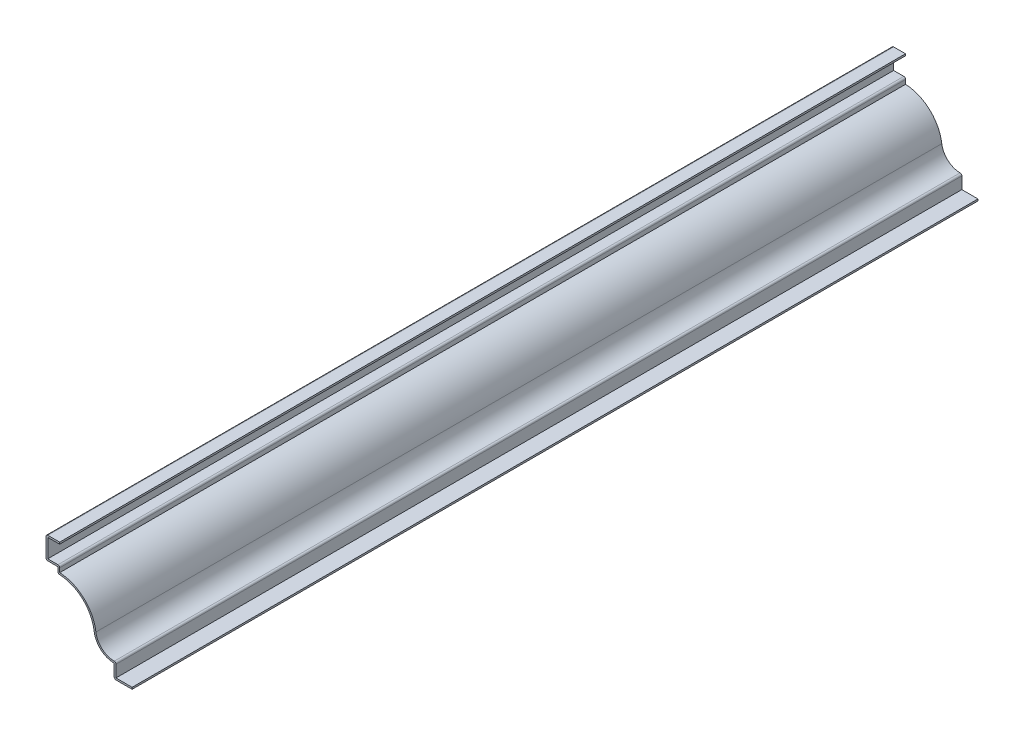
from build123d import *

# Parameters (mm, degrees)
EXTRUDE_THIN1_DEPTH = 787.4
FILLET1_R           = 1.651


with BuildPart() as part:
    # Sketch1 → Extrude-Thin1 (new body)
    with BuildSketch(Plane.XY):
        with BuildLine():
            Line((0, 0), (-16.66875, 0))
            Line((-16.66875, 0), (-16.66875, 12.7))
            ThreePointArc((-16.66875, 12.7), (-29.102138, 17.386858), (-35.347799, 29.114922))
            ThreePointArc((-35.347799, 29.114922), (-46.618799, 50.279536), (-69.05625, 58.7375))
            Line((-69.05625, 58.7375), (-69.05625, 64.29375))
            Line((-69.05625, 64.29375), (-80.16875, 64.29375))
            Line((-80.16875, 64.29375), (-80.16875, 84.93125))
            Line((-80.16875, 84.93125), (-67.46875, 84.93125))
            Line((-67.46875, 84.93125), (-67.46875, 83.28025))
            Line((-67.46875, 83.28025), (-78.51775, 83.28025))
            Line((-78.51775, 83.28025), (-78.51775, 65.94475))
            Line((-78.51775, 65.94475), (-67.40525, 65.94475))
            Line((-67.40525, 65.94475), (-67.40525, 60.35024))
            ThreePointArc((-67.40525, 60.35024), (-44.915012, 50.967453), (-33.710486, 29.327071))
            ThreePointArc((-33.710486, 29.327071), (-27.378357, 18.096412), (-15.01775, 14.430495))
            Line((-15.01775, 14.430495), (-15.01775, 1.651))
            Line((-15.01775, 1.651), (0, 1.651))
            Line((0, 1.651), (0, 0))
        make_face()
    extrude(amount=-EXTRUDE_THIN1_DEPTH)

    # Fillet1
    fillet1_edges = [part.edges().sort_by_distance(p)[0] for p in [
        (-67.40525, 65.94475, -393.7),
        (-15.01775, 14.430495, -393.7),
        (-16.66875, 0, -393.7),
        (-69.05625, 58.7375, -393.7),
        (-80.16875, 64.29375, -393.7),
        (-80.16875, 84.93125, -393.7),
    ]]
    fillet(fillet1_edges, radius=FILLET1_R)


solid = part.part
